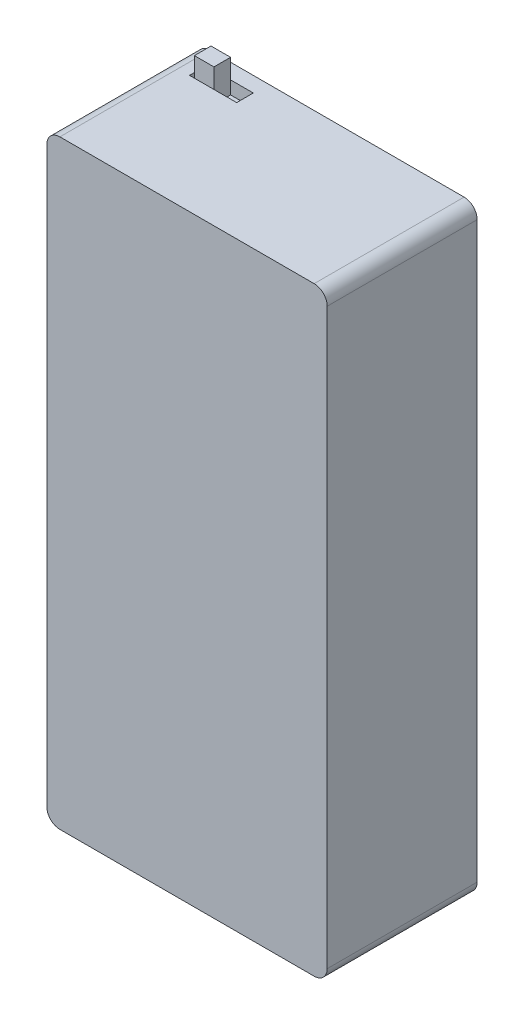
from build123d import *

# Parameters (mm, degrees)
BOSS_EXTRUDE1_DEPTH = 23
SKETCH2_W           = 7.233654816
SKETCH2_H           = 2.549566861
CUT_EXTRUDE1_DEPTH  = 2
SKETCH3_W           = 3
SKETCH3_H           = 2.549566861
BOSS_EXTRUDE2_DEPTH = 5


with BuildPart() as part:
    # Sketch1 → Boss-Extrude1 (new body)
    with BuildSketch(Plane.XY):
        with BuildLine():
            Line((2, 0), (41, 0))
            ThreePointArc((41, 0), (42.414213562, 0.585786438), (43, 2))
            Line((43, 2), (43, 90))
            ThreePointArc((43, 90), (42.414213562, 91.414213562), (41, 92))
            Line((41, 92), (2, 92))
            ThreePointArc((2, 92), (0.585786438, 91.414213562), (0, 90))
            Line((0, 90), (0, 2))
            ThreePointArc((0, 2), (0.585786438, 0.585786438), (2, 0))
        make_face()
    extrude(amount=BOSS_EXTRUDE1_DEPTH)

    # Sketch2 → Cut-Extrude1 (cut)
    with BuildSketch(Plane(origin=(0, 92, 0), x_dir=(1, 0, 0), z_dir=(0, 1, 0))):
        with Locations((7.388443885, -3.61721714)):
            Rectangle(SKETCH2_W, SKETCH2_H)
    extrude(amount=-CUT_EXTRUDE1_DEPTH, mode=Mode.SUBTRACT)

    # Sketch3 → Boss-Extrude2 (add)
    with BuildSketch(Plane(origin=(0, 90, 0), x_dir=(1, 0, 0), z_dir=(0, 1, 0))):
        with Locations((6.019667475, -3.61721714)):
            Rectangle(SKETCH3_W, SKETCH3_H)
    extrude(amount=BOSS_EXTRUDE2_DEPTH)


solid = part.part
